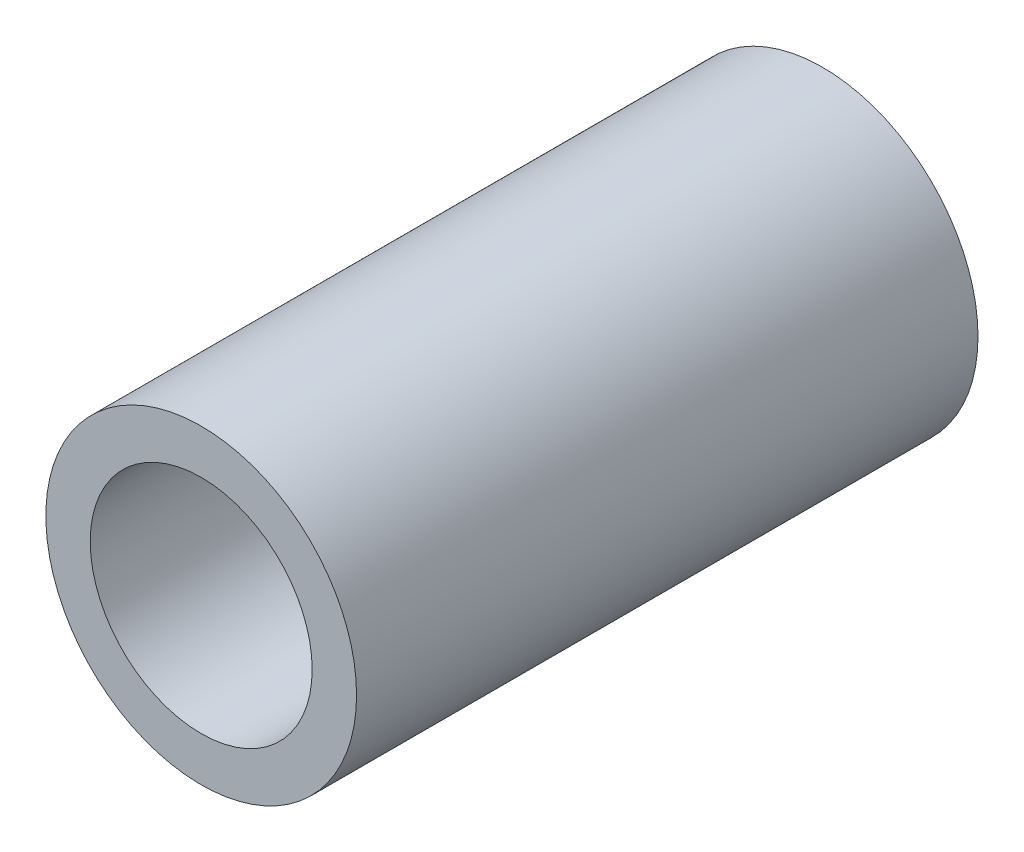
from build123d import *

# Parameters (mm, degrees)
EXTRUDE1_START = -14
SKETCH1_R      = 7
SKETCH1_R_2    = 5
EXTRUDE1_DEPTH = 28


with BuildPart() as part:
    # Sketch1 → Extrude1 (new body)
    with BuildSketch(Plane.XY.offset(EXTRUDE1_START)):
        Circle(SKETCH1_R)
        Circle(SKETCH1_R_2, mode=Mode.SUBTRACT)
    extrude(amount=EXTRUDE1_DEPTH)


solid = part.part
